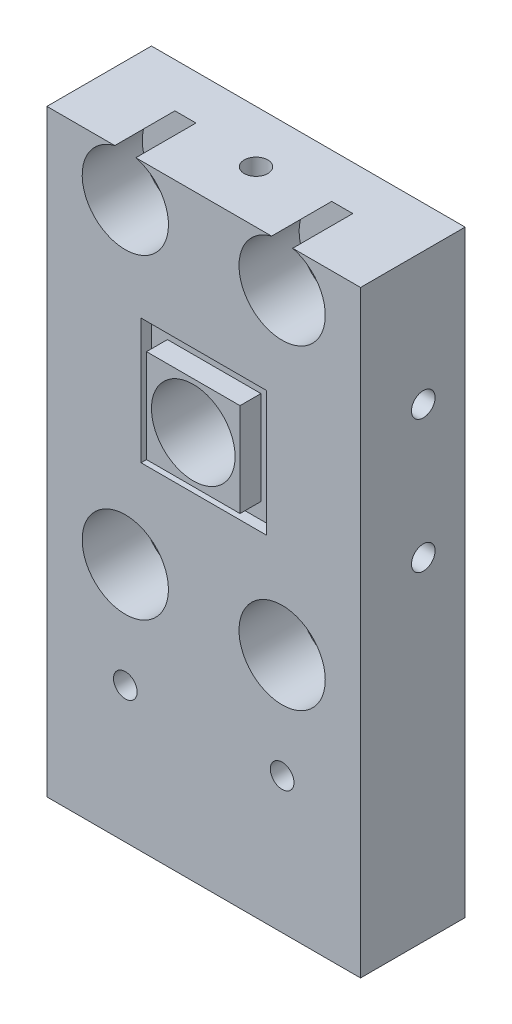
from build123d import *

# Parameters (mm, degrees)
SKETCH1_W                           = 30
SKETCH1_H                           = 57.2
SKETCH1_W_2                         = 11.9888
SKETCH1_H_2                         = 11.9888
BOSS_EXTRUDE1_DEPTH                 = 10
SKETCH1_7_W                         = 11.9888
SKETCH1_7_H                         = 11.9888
SKETCH1_7_W_2                       = 8.9408
SKETCH1_7_H_2                       = 8.9408
BOSS_EXTRUDE2_DEPTH                 = 9
SKETCH1_8_W                         = 8.9408
SKETCH1_8_H                         = 8.9408
SKETCH1_8_R                         = 4
BOSS_EXTRUDE3_DEPTH                 = 11
F_4_40_TAPPED_HOLE1_D               = 2.2606
CUT_EXTRUDE1_START                  = 10
SKETCH3_R                           = 4.125
CUT_EXTRUDE1_DEPTH                  = 5.75
F_4_40_TAPPED_HOLE2_D               = 2.2606
F_4_40_TAPPED_HOLE2_DEPTH           = 7.59
F_4_40_TAPPED_HOLE2_TIP             = 0.679152758
F_4_40_TAPPED_HOLE2_ON_FACE_2_D     = 2.2606
F_4_40_TAPPED_HOLE2_ON_FACE_2_DEPTH = 7.59
F_4_40_TAPPED_HOLE2_ON_FACE_2_TIP   = 0.679152758
F_4_40_TAPPED_HOLE2_ON_FACE_3_D     = 2.2606
F_4_40_TAPPED_HOLE2_ON_FACE_3_DEPTH = 7.59
F_4_40_TAPPED_HOLE2_ON_FACE_3_TIP   = 0.679152758
F_4_40_TAPPED_HOLE2_ON_FACE_4_D     = 2.2606
F_4_40_TAPPED_HOLE2_ON_FACE_4_DEPTH = 7.59
F_4_40_TAPPED_HOLE2_ON_FACE_4_TIP   = 0.679152758


with BuildPart() as part:
    # Sketch1 → Boss-Extrude1 (new body)
    with BuildSketch(Plane.XY):
        with Locations((0, -9.5754)):
            Rectangle(SKETCH1_W, SKETCH1_H)
        Rectangle(SKETCH1_W_2, SKETCH1_H_2, mode=Mode.SUBTRACT)
    extrude(amount=BOSS_EXTRUDE1_DEPTH)

    # Sketch1_7 → Boss-Extrude2 (add)
    with BuildSketch(Plane.XY):
        Rectangle(SKETCH1_7_W, SKETCH1_7_H)
        Rectangle(SKETCH1_7_W_2, SKETCH1_7_H_2, mode=Mode.SUBTRACT)
    extrude(amount=BOSS_EXTRUDE2_DEPTH)

    # Sketch1_8 → Boss-Extrude3 (add)
    with BuildSketch(Plane.XY):
        Rectangle(SKETCH1_8_W, SKETCH1_8_H)
        Circle(SKETCH1_8_R, mode=Mode.SUBTRACT)
    extrude(amount=BOSS_EXTRUDE3_DEPTH)

    # 4-40 Tapped Hole1 (through all)
    with Locations(Plane(origin=(-7.5, 15.0246, 10), x_dir=(1, 0, 0), z_dir=(0, 0, 1))):
        with Locations((0, 0), (15, 0), (0, -30.2), (0, -40.2), (15, -30.2), (15, -40.2)):
            Hole(F_4_40_TAPPED_HOLE1_D / 2)

    # Sketch3 → Cut-Extrude1 (cut)
    with BuildSketch(Plane.XY.offset(CUT_EXTRUDE1_START)):
        with Locations((7.5, -15.1754)):
            Circle(SKETCH3_R)
        Polygon((4.325, -17.008487105), (4.325, -13.342312895), (7.5, -11.509225791), (10.675, -13.342312895), (10.675, -17.008487105), (7.5, -18.841574209), align=None, mode=Mode.SUBTRACT)
        Polygon((4.325, -13.342312895), (7.5, -11.509225791), (10.675, -13.342312895), (10.675, -17.008487105), (7.5, -18.841574209), (4.325, -17.008487105), align=None)
        with Locations((7.5, 15.0246)):
            Circle(SKETCH3_R)
        with Locations((-7.5, 15.0246)):
            Circle(SKETCH3_R)
        with Locations((-7.5, -15.1754)):
            Circle(SKETCH3_R)
    extrude(amount=-CUT_EXTRUDE1_DEPTH, mode=Mode.SUBTRACT)

    # 4-40 Tapped Hole2
    with Locations(Plane(origin=(9, -38.1754, 5), x_dir=(0, 0, -1), z_dir=(0, -1, 0))):
        with Locations((0, 0), (0, -18), (0, -14), (0, -4)):
            Hole(F_4_40_TAPPED_HOLE2_D / 2, depth=F_4_40_TAPPED_HOLE2_DEPTH)
            with Locations((0, 0, -(F_4_40_TAPPED_HOLE2_DEPTH + F_4_40_TAPPED_HOLE2_TIP / 2))):  # 118° drill point
                Cone(0, F_4_40_TAPPED_HOLE2_D / 2, F_4_40_TAPPED_HOLE2_TIP, mode=Mode.SUBTRACT)

    # 4-40 Tapped Hole2 on face 2
    with Locations(Plane(origin=(0, 19.0246, 5), x_dir=(0, 0, 1), z_dir=(0, 1, 0))):
        with Locations((0, 0)):
            Hole(F_4_40_TAPPED_HOLE2_ON_FACE_2_D / 2, depth=F_4_40_TAPPED_HOLE2_ON_FACE_2_DEPTH)
            with Locations((0, 0, -(F_4_40_TAPPED_HOLE2_ON_FACE_2_DEPTH + F_4_40_TAPPED_HOLE2_ON_FACE_2_TIP / 2))):  # 118° drill point
                Cone(0, F_4_40_TAPPED_HOLE2_ON_FACE_2_D / 2, F_4_40_TAPPED_HOLE2_ON_FACE_2_TIP, mode=Mode.SUBTRACT)

    # 4-40 Tapped Hole2 on face 3
    with Locations(Plane(origin=(15, 6.3546, 4), x_dir=(0, 0, 1), z_dir=(1, 0, 0))):
        with Locations((0, 0), (0, 12.7)):
            Hole(F_4_40_TAPPED_HOLE2_ON_FACE_3_D / 2, depth=F_4_40_TAPPED_HOLE2_ON_FACE_3_DEPTH)
            with Locations((0, 0, -(F_4_40_TAPPED_HOLE2_ON_FACE_3_DEPTH + F_4_40_TAPPED_HOLE2_ON_FACE_3_TIP / 2))):  # 118° drill point
                Cone(0, F_4_40_TAPPED_HOLE2_ON_FACE_3_D / 2, F_4_40_TAPPED_HOLE2_ON_FACE_3_TIP, mode=Mode.SUBTRACT)

    # 4-40 Tapped Hole2 on face 4
    with Locations(Plane(origin=(-15, 6.3546, 4), x_dir=(0, 0, -1), z_dir=(-1, 0, 0))):
        with Locations((0, 0), (0, 12.7)):
            Hole(F_4_40_TAPPED_HOLE2_ON_FACE_4_D / 2, depth=F_4_40_TAPPED_HOLE2_ON_FACE_4_DEPTH)
            with Locations((0, 0, -(F_4_40_TAPPED_HOLE2_ON_FACE_4_DEPTH + F_4_40_TAPPED_HOLE2_ON_FACE_4_TIP / 2))):  # 118° drill point
                Cone(0, F_4_40_TAPPED_HOLE2_ON_FACE_4_D / 2, F_4_40_TAPPED_HOLE2_ON_FACE_4_TIP, mode=Mode.SUBTRACT)


solid = part.part
